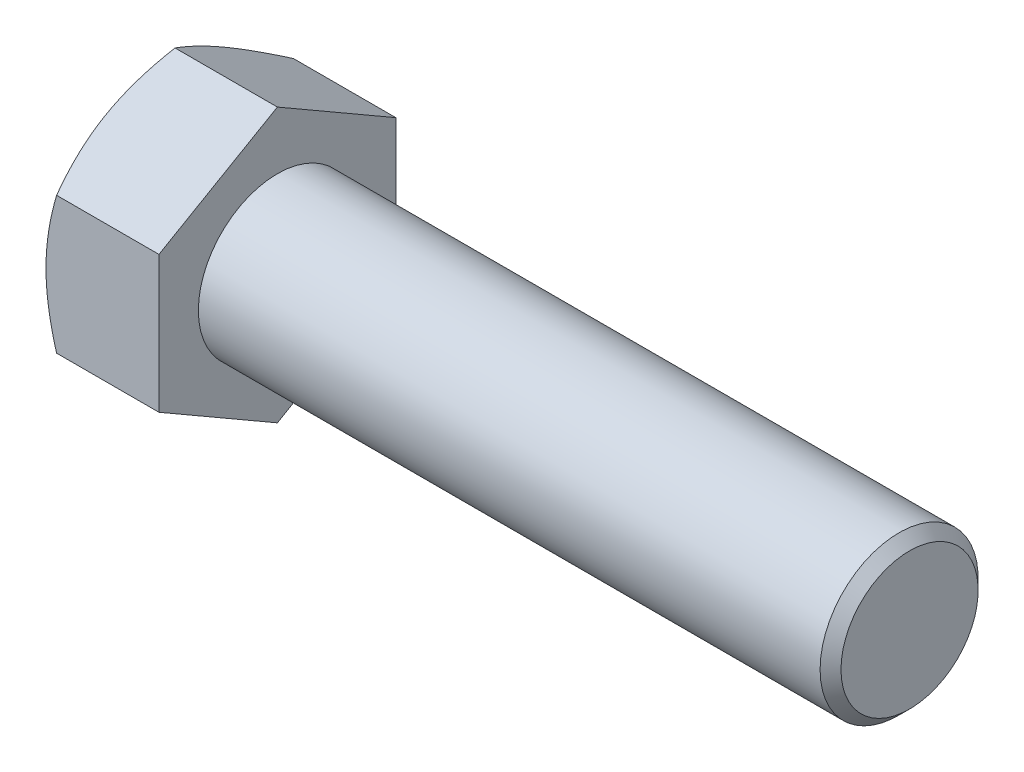
from build123d import *

# Parameters (mm, degrees)
BASEHEAD_DEPTH = 6.8072


with BuildPart() as part:
    # Sketch1 → BaseHead (new body)
    with BuildSketch(Plane(origin=(0, 0, 0), x_dir=(0, 0, -1), z_dir=(1, 0, 0))):
        Polygon((7.1374, 4.120779811), (7.1374, -4.120779811), (0, -8.241559623), (-7.1374, -4.120779811), (-7.1374, 4.120779811), (0, 8.241559623), align=None)
    extrude(amount=BASEHEAD_DEPTH)

    # BodySke → BaseBody (revolve)
    with BuildSketch(Plane.XY):
        Polygon((0, 0), (44.9072, 0), (44.9072, 4.13258), (44.27728, 4.7625), (0, 4.7625), align=None)
    revolve(axis=Axis((0, 0, 0), (1, 0, 0)))

    # Sketch3 → HeadChamfer (revolve, cut)
    with BuildSketch(Plane.XY):
        Polygon((0, 7.1374), (4.303661065, 14.591559623), (4.303661065, 20.941559623), (-12.7, 20.941559623), (-12.7, 7.1374), align=None)
    revolve(axis=Axis((0, 0, 0), (1, 0, 0)), mode=Mode.SUBTRACT)


solid = part.part
